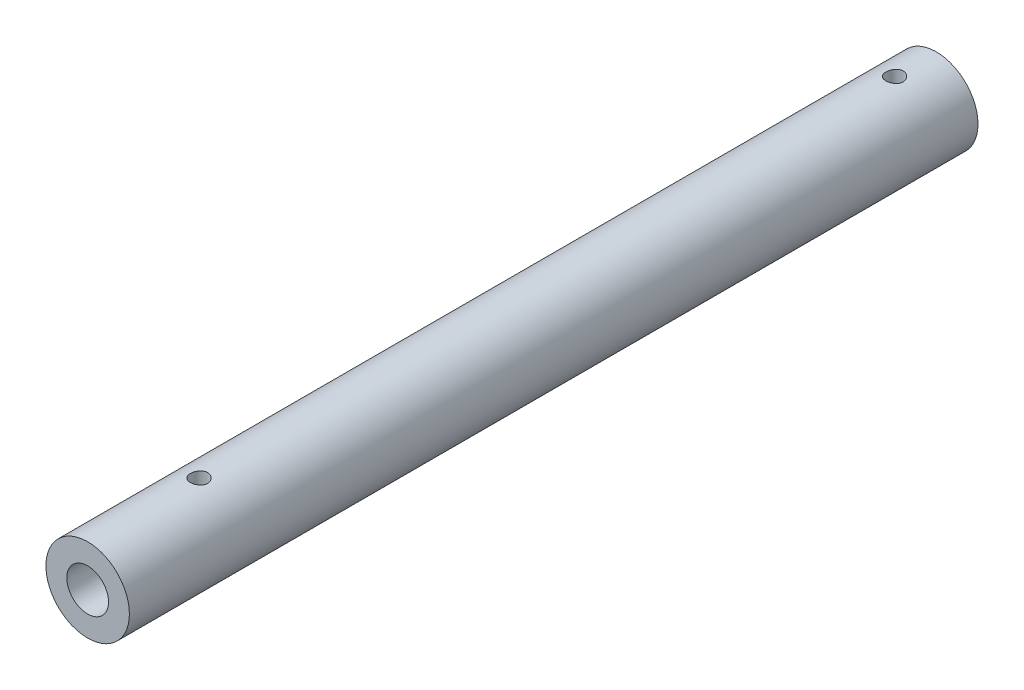
from build123d import *

# Parameters (mm, degrees)
BOSS_EXTRUDE1_DEPTH      = 152.5
BOSS_EXTRUDE1_DEPTH_BACK = 152.5
SKETCH1_R                = 15
SKETCH1_R_2              = 7.5
SKETCH2_R                = 3.1
CUT_EXTRUDE1_DEPTH       = 154.968340902
SKETCH3_R                = 3.1
CUT_EXTRUDE2_DEPTH       = 154.96834102


with BuildPart() as part:
    # Sketch1 → Boss-Extrude1 (new, two sides: drawn at the far end of the back side and taken through both)
    with BuildSketch(Plane.XY.offset(-BOSS_EXTRUDE1_DEPTH_BACK)):
        Circle(SKETCH1_R)
        Circle(SKETCH1_R_2, mode=Mode.SUBTRACT)
    extrude(amount=BOSS_EXTRUDE1_DEPTH + BOSS_EXTRUDE1_DEPTH_BACK)

    # Sketch2 → Cut-Extrude1 (cut, through all)
    with BuildSketch(Plane(origin=(0, 0, 0), x_dir=(1, 0, 0), z_dir=(0, 1, 0))):
        with Locations((0, -112.5)):
            Circle(SKETCH2_R)
    extrude(amount=CUT_EXTRUDE1_DEPTH, mode=Mode.SUBTRACT)

    # Sketch3 → Cut-Extrude2 (cut, through all)
    with BuildSketch(Plane(origin=(0, 0, 0), x_dir=(1, 0, 0), z_dir=(0, 1, 0))):
        with Locations((0, 137.5)):
            Circle(SKETCH3_R)
    extrude(amount=CUT_EXTRUDE2_DEPTH, mode=Mode.SUBTRACT)


solid = part.part
